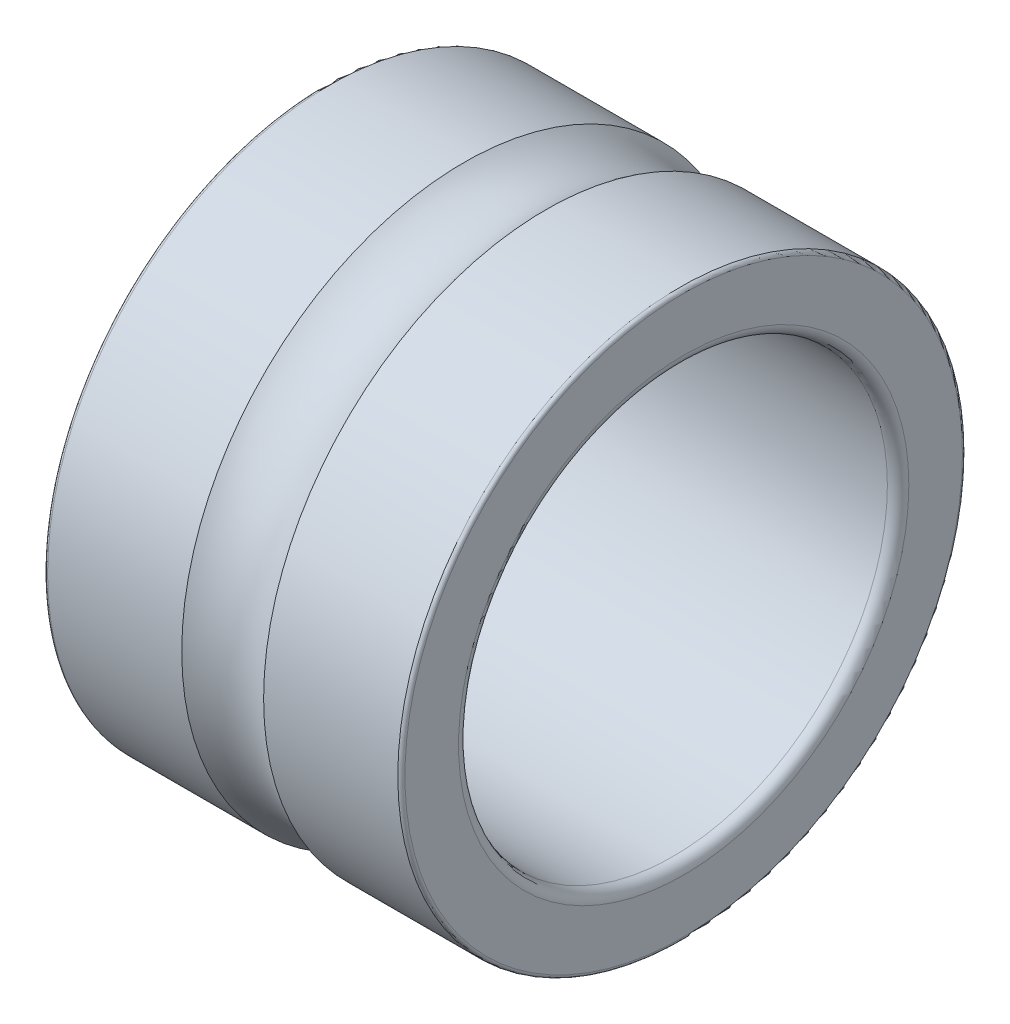
from build123d import *


with BuildPart() as part:
    # Sketch1 → Revolve1 (revolve)
    with BuildSketch(Plane.XY):
        with BuildLine():
            Line((0, 3.9), (0, 3.15))
            ThreePointArc((0, 3.15), (0.043933983, 3.043933983), (0.15, 3))
            Line((0.15, 3), (4.85, 3))
            ThreePointArc((4.85, 3), (4.956066017, 3.043933983), (5, 3.15))
            Line((5, 3.15), (5, 3.9))
            ThreePointArc((5, 3.9), (4.985355339, 3.935355339), (4.95, 3.95))
            Line((4.95, 3.95), (3.072681412, 3.95))
            ThreePointArc((3.072681412, 3.95), (2.5, 3.768), (1.927318588, 3.95))
            Line((1.927318588, 3.95), (0.05, 3.95))
            ThreePointArc((0.05, 3.95), (0.014644661, 3.935355339), (0, 3.9))
        make_face()
    revolve(axis=Axis((4.85, 0, 0), (-1, 0, 0)))


solid = part.part
